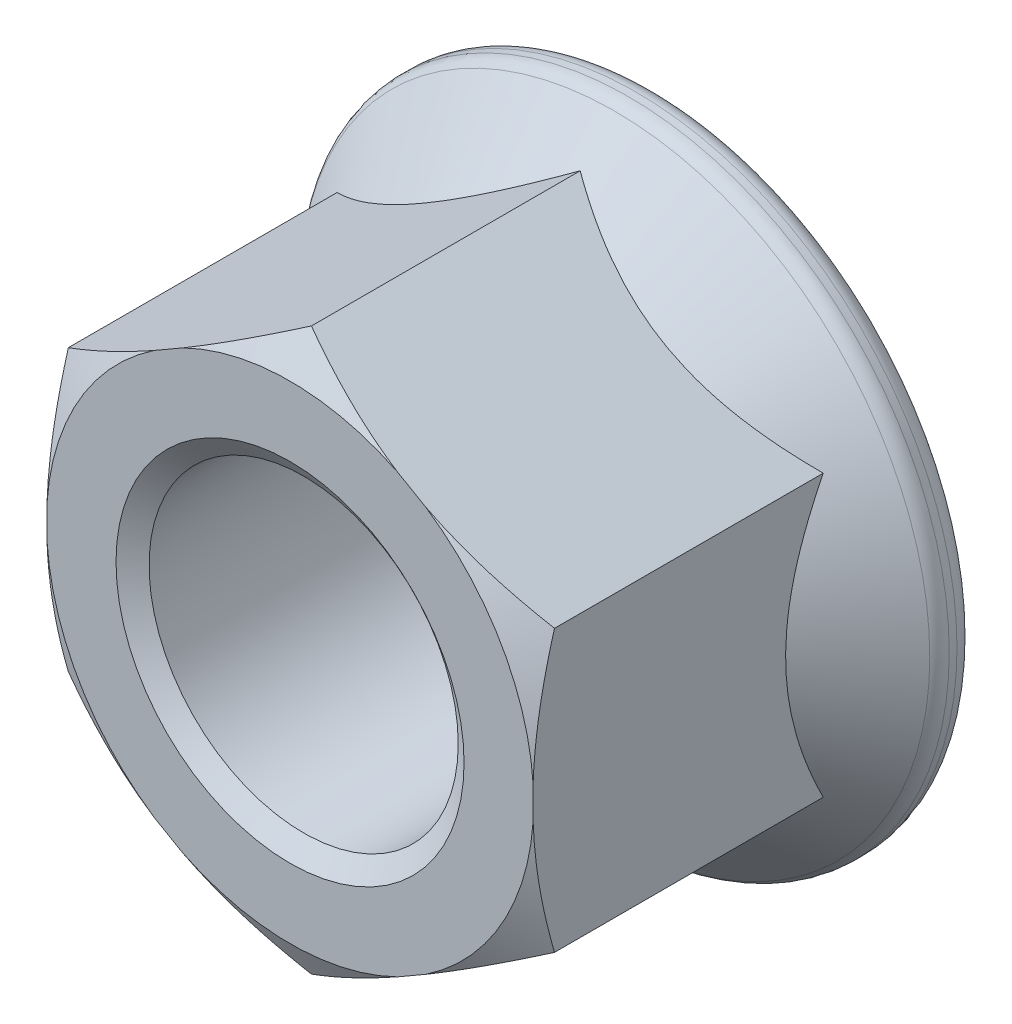
from build123d import *

# Parameters (mm, degrees)
C_EXT_HEX_REACH = 9.611
SKETCH2_R       = 3.793174209


with BuildPart() as part:
    # Sketch1 → Revolve1 (revolve)
    with BuildSketch(Plane(origin=(0, 0, 0), x_dir=(0, -1, 0), z_dir=(1, 0, 0)), mode=Mode.PRIVATE) as revolve1_sk:
        with BuildLine():
            Line((2.273224716, 0), (3.182239192, 0))
            Line((3.182239192, 0), (3.666174188, 0.2794))
            Line((3.666174188, 0.2794), (3.666174188, 3.789511232))
            Line((3.666174188, 3.789511232), (4.116605118, 4.239942163))
            ThreePointArc((4.116605118, 4.239942163), (4.171665397, 4.322345693), (4.190999996, 4.419547285))
            Line((4.190999996, 4.419547285), (4.190999996, 4.521147285))
            ThreePointArc((4.190999996, 4.521147285), (4.116605118, 4.700752408), (3.936999996, 4.775147285))
            Line((3.936999996, 4.775147285), (2.197152715, 4.775147285))
            Line((2.197152715, 4.775147285), (2.0193, 4.521147285))
            Line((2.0193, 4.521147285), (2.0193, 0.1778))
            Line((2.0193, 0.1778), (2.273224716, 0))
        make_face()
    revolve(revolve1_sk.sketch.rotate(Axis((0, 0, 0), (0, 0, -1)), 270), axis=Axis((0, 0, 0), (0, 0, -1)))

    # C-Ext Hex: up to this cone (the profile starts outside it)
    c_ext_hex_end = Plane(origin=(0, 0, 0), z_dir=(0, 0, -1)).offset(0.123338045) * Cone(1e-06, 9.987662955, 9.987661955, align=(Align.CENTER, Align.CENTER, Align.MIN), mode=Mode.PRIVATE)
    # Sketch2 → C-Ext Hex (cut, up to the surface)
    with BuildSketch(Plane.XY, mode=Mode.PRIVATE) as c_ext_hex_sk1:
        Circle(SKETCH2_R)
        Polygon((0, 3.666174209), (-3.175, 1.833087105), (-3.175, -1.833087105), (0, -3.666174209), (3.175, -1.833087105), (3.175, 1.833087105), align=None, mode=Mode.SUBTRACT)
    c_ext_hex_tool1 = extrude(c_ext_hex_sk1.sketch, amount=-C_EXT_HEX_REACH, mode=Mode.PRIVATE) - c_ext_hex_end
    add(c_ext_hex_tool1.solids().sort_by_distance((-3.685887, 0, 0))[0], mode=Mode.SUBTRACT)


solid = part.part
